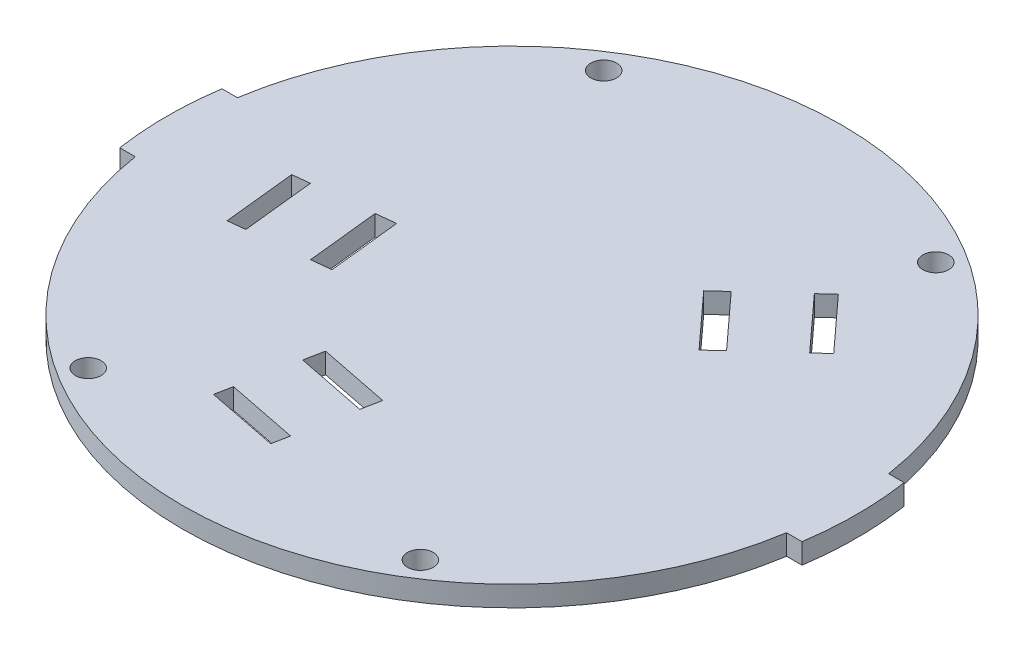
from build123d import *

# Parameters (mm, degrees)
BOSS_EXTRUDE1_DEPTH        = 4
F_8_0_199_DIAMETER_HOLE6_D = 5.0546
CUT_EXTRUDE1_DEPTH         = 4


with BuildPart() as part:
    # Sketch1 → Boss-Extrude1 (new body)
    with BuildSketch(Plane(origin=(0, 0, 0), x_dir=(1, 0, 0), z_dir=(0, 1, 0))):
        with BuildLine():
            Line((-63.720091023, -12.396555886), (-66.755149614, -12.396555886))
            ThreePointArc((-66.755149614, -12.396555886), (-67.5, -2.396555886), (-66.755149614, 7.603444114))
            Line((-66.755149614, 7.603444114), (-63.720091023, 7.603444114))
            ThreePointArc((-63.720091023, 7.603444114), (0, 62.103444114), (63.720091023, 7.603444114))
            Line((63.720091023, 7.603444114), (66.755149614, 7.603444114))
            ThreePointArc((66.755149614, 7.603444114), (67.5, -2.396555886), (66.755149614, -12.396555886))
            Line((66.755149614, -12.396555886), (63.720091023, -12.396555886))
            ThreePointArc((63.720091023, -12.396555886), (0, -66.896555886), (-63.720091023, -12.396555886))
        make_face()
    extrude(amount=-BOSS_EXTRUDE1_DEPTH)

    # #8 (0.199) Diameter Hole6 (through all)
    with Locations(Plane(origin=(-32.5, -4, 52.832158391), x_dir=(0, 0, -1), z_dir=(0, -1, 0))):
        with Locations((0, 0), (0, 65), (100.871205009, 65), (100.871205009, 0)):
            Hole(F_8_0_199_DIAMETER_HOLE6_D / 2)

    # Sketch4 → Cut-Extrude1 (cut)
    with BuildSketch(Plane.XZ.offset(4)):
        Polygon((17.425968137, -23.074858179), (14.612549904, -20.505660279), (24.204222064, -10.002232211), (27.017640296, -12.571430111), align=None)
        Polygon((28.385745934, -33.083266376), (25.92935527, -30.840104068), (35.52102743, -20.336676), (37.977418094, -22.579838308), align=None)
        Polygon((-26.832584157, -1.852037702), (-30.62128677, -1.449753587), (-29.119426074, 12.694736168), (-25.330723461, 12.292452053), align=None)
        Polygon((-42.072412194, -0.233874083), (-45.380321989, 0.117359492), (-43.878461293, 14.261849248), (-40.570551498, 13.910615673), align=None)
        Polygon((1.801240517, 29.503633423), (-12.149127519, 26.727051412), (-12.892854843, 30.463757136), (1.057513193, 33.240339147), align=None)
        Polygon((-1.190357845, 44.534307106), (-15.14072588, 41.757725095), (-15.79007294, 45.020236494), (-1.839704904, 47.796818505), align=None)
    extrude(amount=-CUT_EXTRUDE1_DEPTH, mode=Mode.SUBTRACT)


solid = part.part
